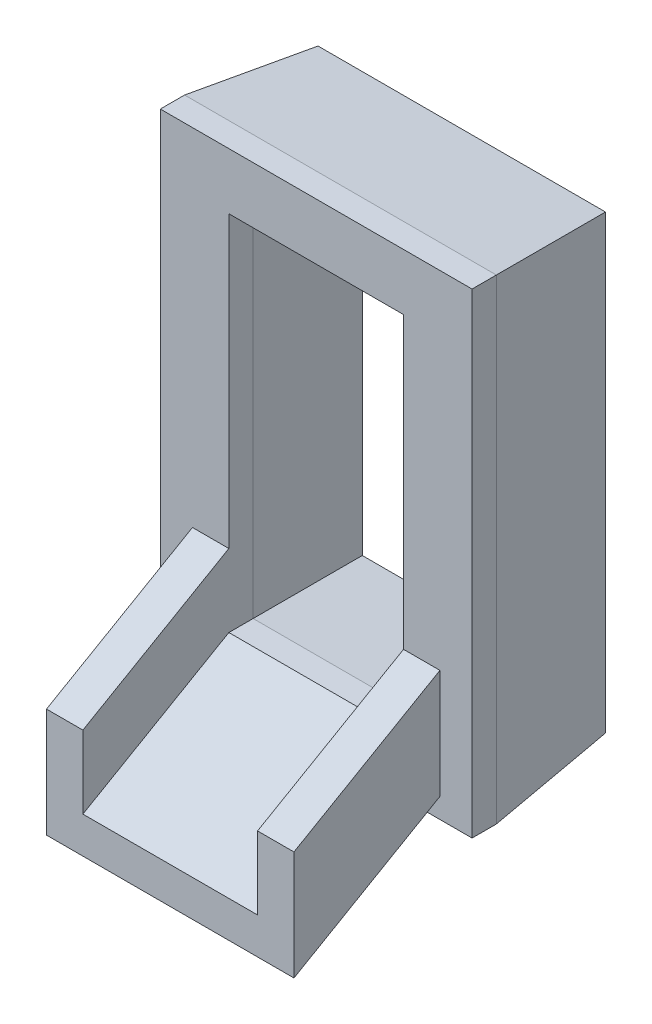
from build123d import *

# Parameters (mm, degrees)
SKETCH3_W           = 25.7
SKETCH3_H           = 39.2
SKETCH3_W_2         = 14.4
SKETCH3_H_2         = 29.9
BOSS_EXTRUDE2_DEPTH = 12
CHAMFER1_SIZE       = 1
CHAMFER1_SIZE2      = 10


with BuildPart() as part:
    # Sketch3 → Boss-Extrude2 (new body)
    with BuildSketch(Plane.XY):
        with Locations((12.85, 19.6)):
            Rectangle(SKETCH3_W, SKETCH3_H)
        with Locations((12.85, 19.6)):
            Rectangle(SKETCH3_W_2, SKETCH3_H_2, mode=Mode.SUBTRACT)
    extrude(amount=BOSS_EXTRUDE2_DEPTH)

    # Chamfer1
    chamfer1_edges = [part.edges().sort_by_distance(p)[0] for p in [
        (5.65, 19.6, 0),
        (12.85, 4.65, 0),
        (20.05, 19.6, 0),
        (12.85, 34.55, 0),
        (12.85, 39.2, 0),
        (25.7, 19.6, 0),
        (12.85, 0, 0),
        (0, 19.6, 0),
    ]]
    chamfer1_side = [part.faces().sort_by_distance(p)[0] for p in [
        (12.85, 0.468735533, 0),
    ]]
    chamfer(chamfer1_edges, length=CHAMFER1_SIZE, length2=CHAMFER1_SIZE2, reference=chamfer1_side[0])

    # Sweep1: sweep along a path in Sketch6
    with BuildLine(Plane.ZY.offset(-12.85)) as sweep1_path:
        Line((12, 4.65), (24.033327649, -2.297444957))
    # Sketch4 → Sweep1 (sweep)
    with BuildSketch(Plane.XY.offset(12)):
        Polygon((5.65, 10.65), (2.65, 10.65), (2.65, 1.65), (23.05, 1.65), (23.05, 10.65), (20.05, 10.65), (20.05, 4.65), (5.65, 4.65), align=None)
    sweep(path=sweep1_path.line)


solid = part.part
